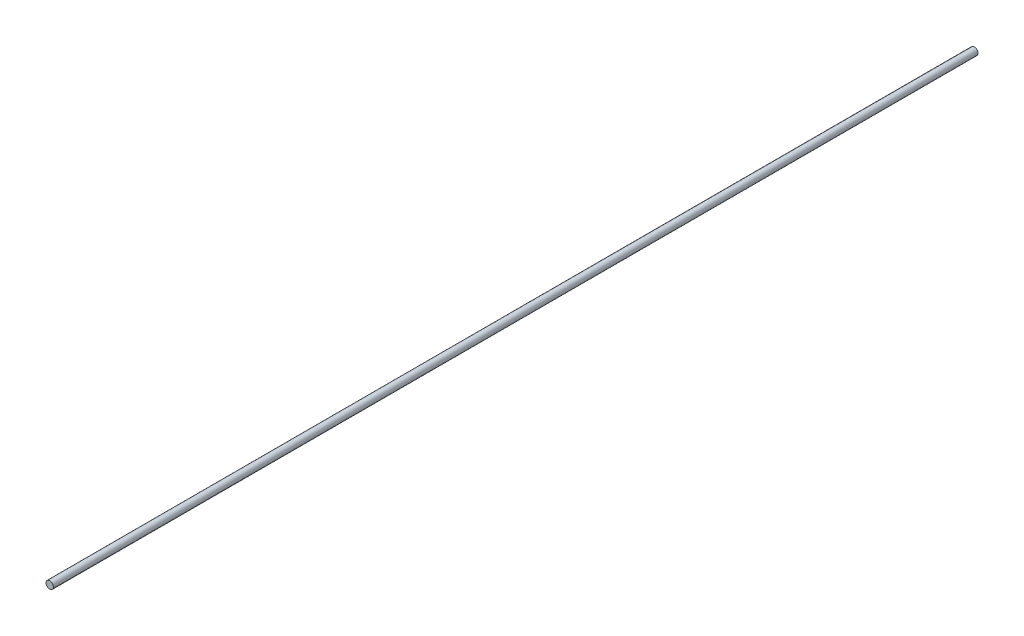
from build123d import *

# Parameters (mm, degrees)
SKETCH1_R           = 0.975
BOSS_EXTRUDE1_DEPTH = 244.38
SKETCH2_W           = 1
SKETCH2_H           = 1
CUT_EXTRUDE1_DEPTH  = 5


with BuildPart() as part:
    # Sketch1 → Boss-Extrude1 (new body)
    with BuildSketch(Plane.XY):
        Circle(SKETCH1_R)
    extrude(amount=BOSS_EXTRUDE1_DEPTH)

    # Sketch2 → Cut-Extrude1 (cut)
    with BuildSketch(Plane.XY):
        Rectangle(SKETCH2_W, SKETCH2_H)
    extrude(amount=CUT_EXTRUDE1_DEPTH, mode=Mode.SUBTRACT)


solid = part.part
